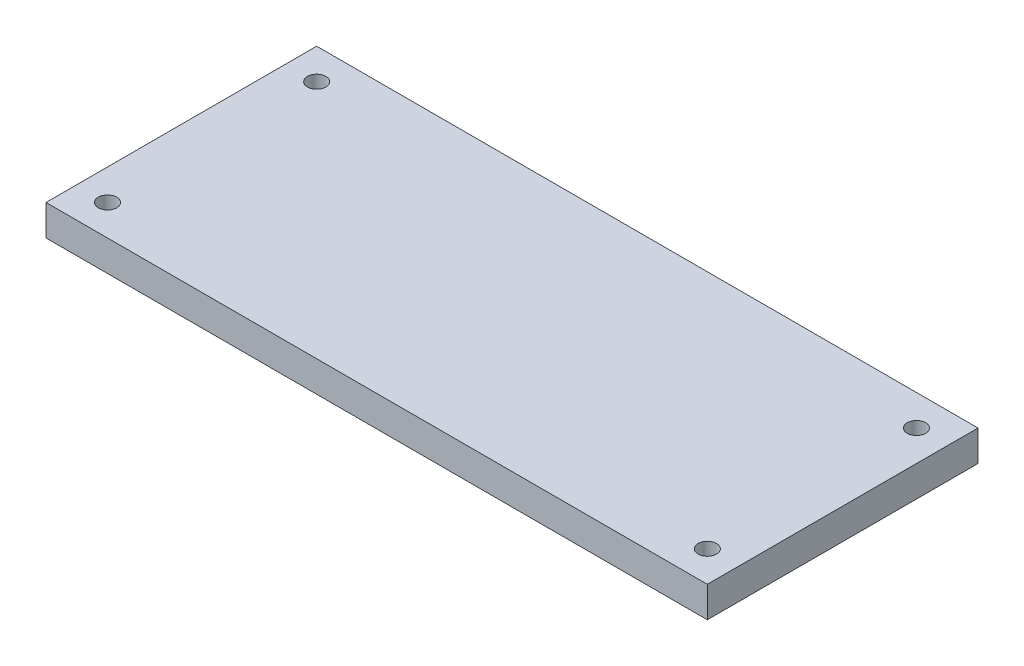
from build123d import *

# Parameters (mm, degrees)
SKETCH1_W           = 215
SKETCH1_H           = 88
SKETCH1_R           = 3
BOSS_EXTRUDE1_DEPTH = 10


with BuildPart() as part:
    # Sketch1 → Boss-Extrude1 (new body)
    with BuildSketch(Plane(origin=(0, 0, 0), x_dir=(1, 0, 0), z_dir=(0, 1, 0))):
        with Locations((107.5, 44)):
            Rectangle(SKETCH1_W, SKETCH1_H)
        with Locations((10, 78)):
            Circle(SKETCH1_R, mode=Mode.SUBTRACT)
        with Locations((10, 10)):
            Circle(SKETCH1_R, mode=Mode.SUBTRACT)
        with Locations((205, 78)):
            Circle(SKETCH1_R, mode=Mode.SUBTRACT)
        with Locations((205, 10)):
            Circle(SKETCH1_R, mode=Mode.SUBTRACT)
    extrude(amount=BOSS_EXTRUDE1_DEPTH)


solid = part.part
